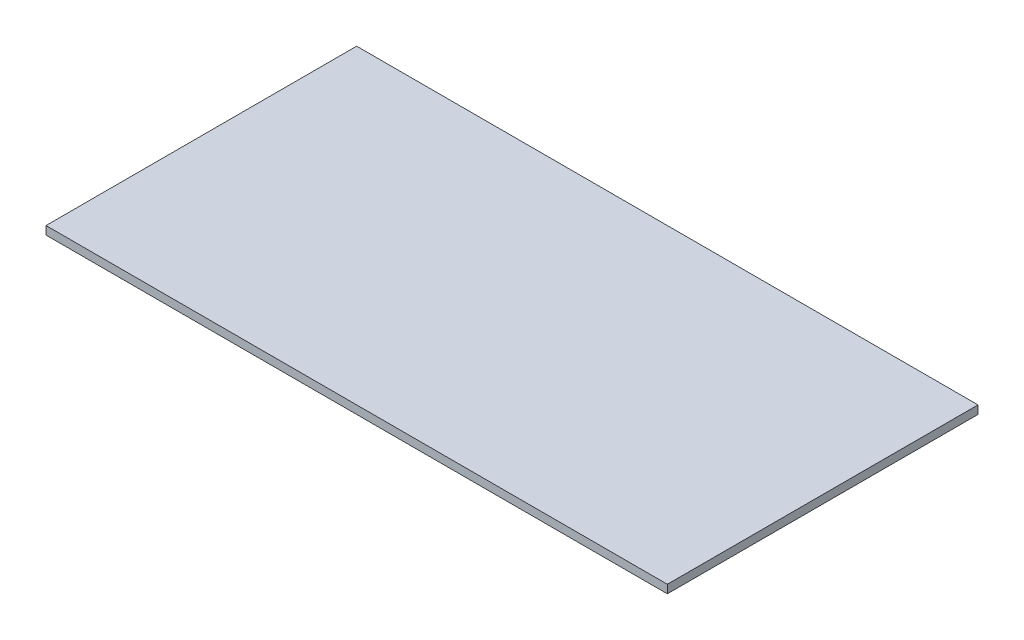
from build123d import *

# Parameters (mm, degrees)
SKETCH1_W           = 1500
SKETCH1_H           = 750
BOSS_EXTRUDE1_DEPTH = 20


with BuildPart() as part:
    # Sketch1 → Boss-Extrude1 (new body)
    with BuildSketch(Plane(origin=(0, 0, 0), x_dir=(1, 0, 0), z_dir=(0, 1, 0))):
        Rectangle(SKETCH1_W, SKETCH1_H)
    extrude(amount=BOSS_EXTRUDE1_DEPTH)


solid = part.part
